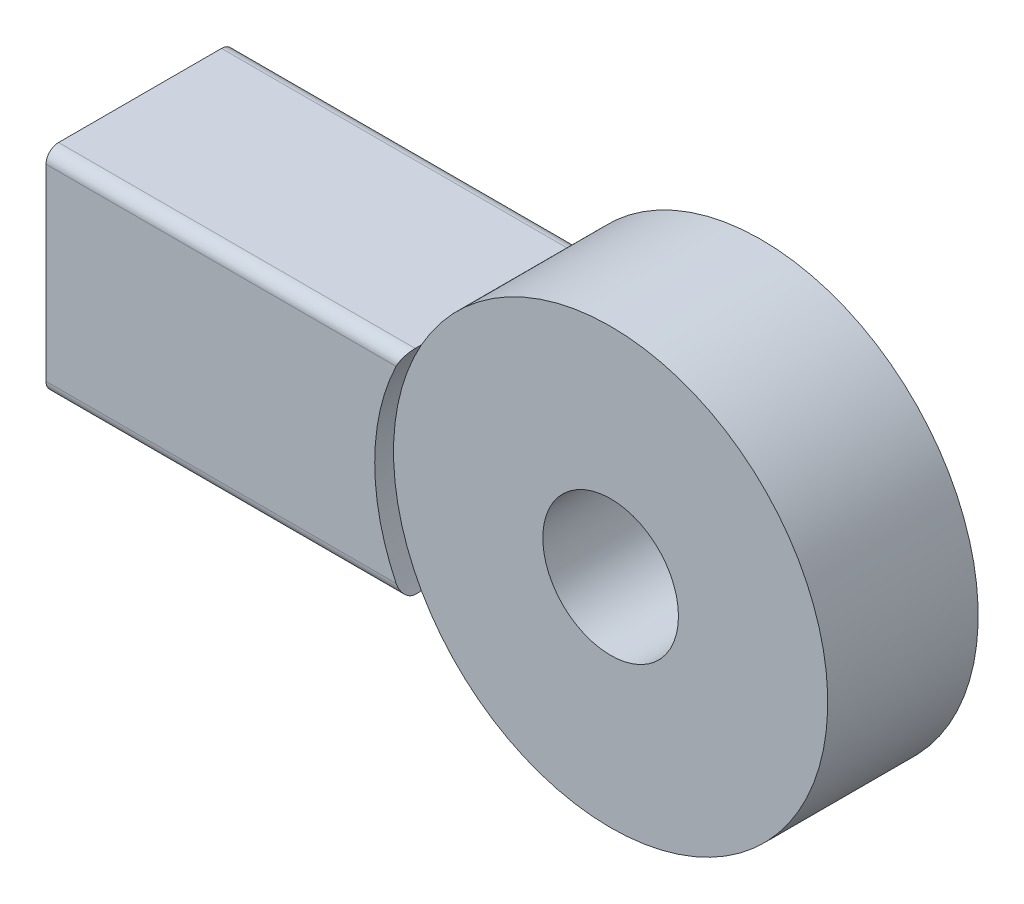
from build123d import *

# Parameters (mm, degrees)
SKETCH1_R           = 5.411731441
BOSS_EXTRUDE1_DEPTH = 6
BOSS_EXTRUDE2_DEPTH = 7.5
SKETCH2_W           = 11
SKETCH2_H           = 12.996419178
CUT_EXTRUDE1_DEPTH  = 26
FILLET1_R           = 1


with BuildPart() as part:
    # Sketch1 → Boss-Extrude1 (new, symmetric)
    with BuildSketch(Plane.XY):
        with BuildLine():
            ThreePointArc((-15.090527346, 8.498209589), (-17.318879346, 0), (-15.090527346, -8.498209589))
            ThreePointArc((-15.090527346, -8.498209589), (4.39275309, -16.752531214), (17.318879346, 0))
            ThreePointArc((17.318879346, 0), (4.39275309, 16.752531214), (-15.090527346, 8.498209589))
        make_face()
        Circle(SKETCH1_R, mode=Mode.SUBTRACT)
    extrude(amount=BOSS_EXTRUDE1_DEPTH, both=True)

    # Sketch1_3 → Boss-Extrude2 (add, symmetric)
    with BuildSketch(Plane.XY):
        with BuildLine():
            Line((-43.539982068, -8.498209589), (-15.090527346, -8.498209589))
            ThreePointArc((-15.090527346, -8.498209589), (-17.318879346, 0), (-15.090527346, 8.498209589))
            Line((-15.090527346, 8.498209589), (-43.539982068, 8.498209589))
            Line((-43.539982068, 8.498209589), (-43.539982068, -8.498209589))
        make_face()
    extrude(amount=BOSS_EXTRUDE2_DEPTH, both=True)

    # Sketch2 → Cut-Extrude1 (cut)
    with BuildSketch(Plane.ZY.offset(43.539982068)):
        Rectangle(SKETCH2_W, SKETCH2_H)
    extrude(amount=-CUT_EXTRUDE1_DEPTH, mode=Mode.SUBTRACT)

    # Fillet1
    fillet1_edges = [part.edges().sort_by_distance(p)[0] for p in [
        (-29.315254707, 8.498209589, -7.5),
        (-29.315254707, -8.498209589, -7.5),
        (-29.315254707, 8.498209589, 7.5),
        (-29.315254707, -8.498209589, 7.5),
    ]]
    fillet(fillet1_edges, radius=FILLET1_R)


solid = part.part
